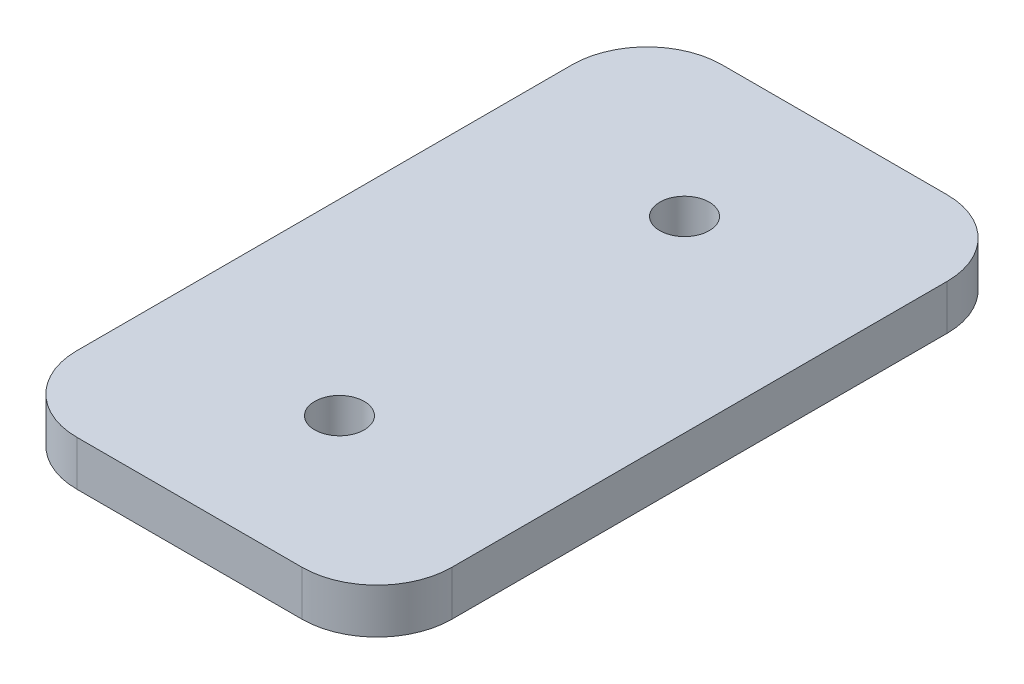
from build123d import *

# Parameters (mm, degrees)
SKETCH1_W                = 50
SKETCH1_H                = 6
BOSS_EXTRUDE1_DEPTH      = 40
BOSS_EXTRUDE1_DEPTH_BACK = 46
SKETCH2_R                = 3.3
CUT_EXTRUDE1_DEPTH       = 7
FILLET1_R                = 10


with BuildPart() as part:
    # Sketch1 → Boss-Extrude1 (new body, two sides)
    with BuildSketch(Plane.XY) as boss_extrude1_sk:
        with Locations((371.231060123, 22)):
            Rectangle(SKETCH1_W, SKETCH1_H)
    extrude(amount=BOSS_EXTRUDE1_DEPTH)
    extrude(boss_extrude1_sk.sketch, amount=-BOSS_EXTRUDE1_DEPTH_BACK)

    # Sketch2 → Cut-Extrude1 (cut, through all)
    with BuildSketch(Plane.XZ.offset(-19)):
        with Locations((371.231060123, -26)):
            Circle(SKETCH2_R)
        with Locations((371.231060123, 20)):
            Circle(SKETCH2_R)
    extrude(amount=-CUT_EXTRUDE1_DEPTH, mode=Mode.SUBTRACT)

    # Fillet1
    fillet1_edges = [part.edges().sort_by_distance(p)[0] for p in [
        (396.231060123, 22, -46),
        (346.231060123, 22, 40),
        (396.231060123, 22, 40),
        (346.231060123, 22, -46),
    ]]
    fillet(fillet1_edges, radius=FILLET1_R)


solid = part.part
